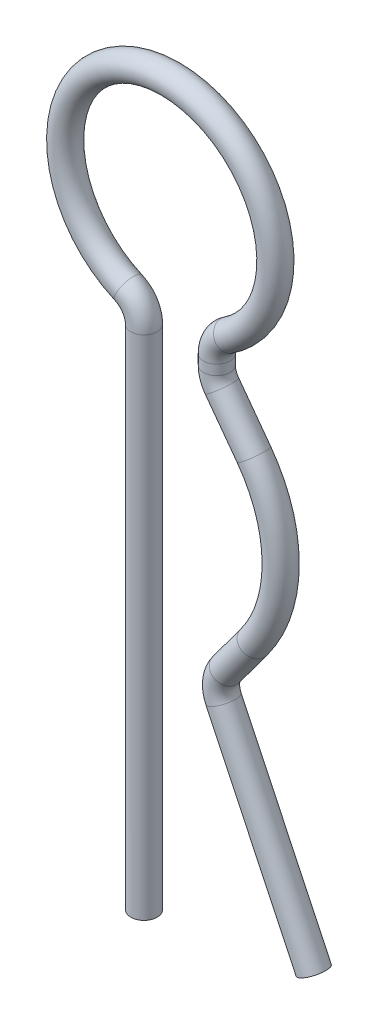
from build123d import *

# Parameters (mm, degrees)
ESQUISSE2_R = 0.25


with BuildPart() as part:
    # Base-Balayage: sweep along a path in Esquisse1
    with BuildLine(Plane.XY) as base_balayage_path:
        Line((0, -7), (0, 2.645203826))
        ThreePointArc((0, 2.645203826), (-0.081669987, 2.919065104), (-0.3, 3.103461395))
        ThreePointArc((-0.3, 3.103461395), (0.324563694, 6.92878234), (1.608029318, 3.271477851))
        ThreePointArc((1.608029318, 3.271477851), (1.444296552, 3.091334894), (1.385036648, 2.855224395))
        Line((1.385036648, 2.855224395), (1.385036648, 2.66624628))
        ThreePointArc((1.385036648, 2.66624628), (1.410092076, 2.509952795), (1.482747263, 2.36932331))
        Line((1.482747263, 2.36932331), (2.091904805, 1.543999446))
        ThreePointArc((2.091904805, 1.543999446), (2.6, 0), (2.091904805, -1.543999446))
        Line((2.091904805, -1.543999446), (1.562806978, -2.260853514))
        ThreePointArc((1.562806978, -2.260853514), (1.467415935, -2.509670445), (1.51338468, -2.772151283))
        Line((1.51338468, -2.772151283), (3.228383069, -6.385844758))
    # Esquisse2 → Base-Balayage (sweep)
    with BuildSketch(Plane(origin=(0, -7, 0), x_dir=(-1, 0, 0), z_dir=(0, 1, 0))):
        Circle(ESQUISSE2_R)
    sweep(path=base_balayage_path.line)


solid = part.part
